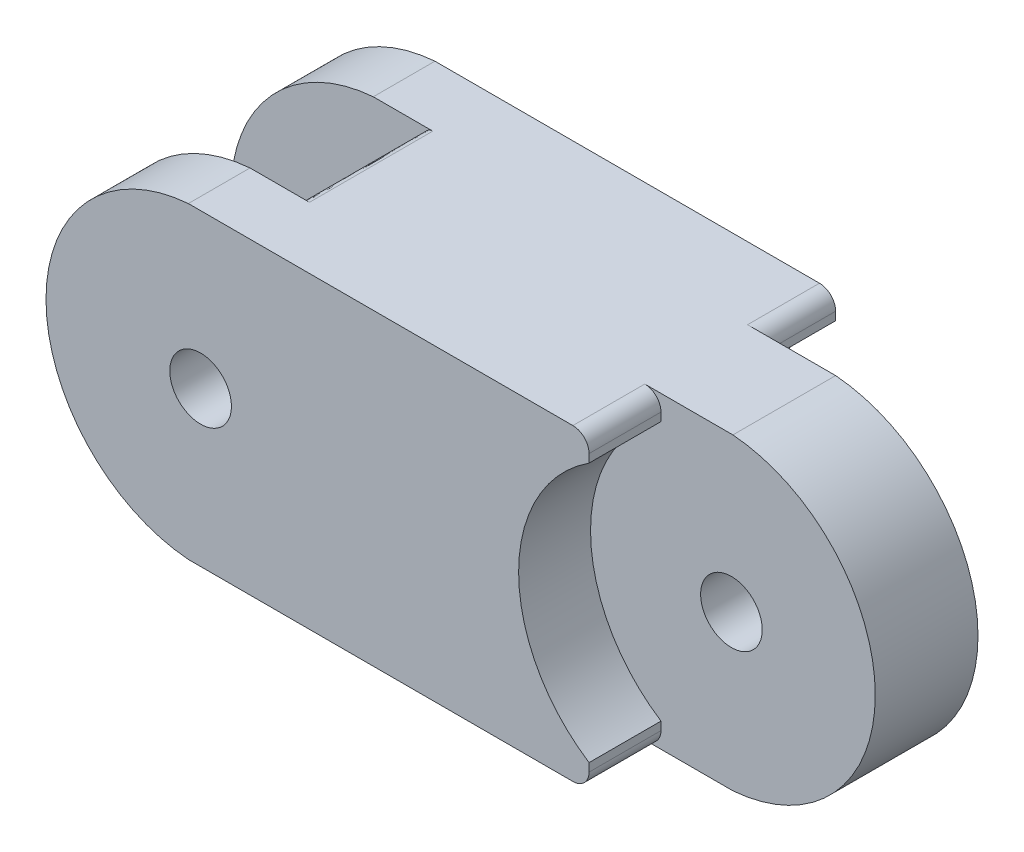
from build123d import *

# Parameters (mm, degrees)
SKETCH1_W               = 29.21
SKETCH1_H               = 15.24
BOSS_EXTRUDE1_DEPTH     = 19.05
BOSS_EXTRUDE2_DEPTH     = 3.175
BOSS_EXTRUDE3_DEPTH     = 3.81
LPATTERN1_COUNT         = 2
LPATTERN1_PITCH         = 11.43
SKETCH7_R               = 1.905
CUT_EXTRUDE2_DEPTH      = 8.62
CUT_EXTRUDE2_DEPTH_BACK = 8.62
CUT_EXTRUDE4_DEPTH      = 2.794
CUT_EXTRUDE4_DEPTH_BACK = 3.175
CUT_EXTRUDE5_DEPTH      = 5.842
CUT_EXTRUDE6_DEPTH      = 3.81
FILLET2_R               = 0.5
SKETCH16_R              = 1.905
CUT_EXTRUDE8_DEPTH      = 2.27
CUT_EXTRUDE8_DEPTH_BACK = 14.97
SKETCH17_W              = 4.445
SKETCH17_H              = 4.445
CUT_EXTRUDE9_DEPTH      = 19.05
LPATTERN2_COUNT         = 2
LPATTERN2_PITCH         = 10.795
FILLET4_R               = 1


with BuildPart() as part:
    # Sketch1 → Boss-Extrude1 (new body)
    with BuildSketch(Plane(origin=(0, 0, 0), x_dir=(1, 0, 0), z_dir=(0, 1, 0))):
        Rectangle(SKETCH1_W, SKETCH1_H)
    extrude(amount=BOSS_EXTRUDE1_DEPTH)

    # Sketch3 → Boss-Extrude2 (add, symmetric)
    with BuildSketch(Plane.XY):
        with BuildLine():
            Line((14.605, 19.05), (14.605, 0))
            ThreePointArc((14.605, 0), (23.403337922, 9.525), (14.605, 19.05))
        make_face()
    extrude(amount=BOSS_EXTRUDE2_DEPTH, both=True)

    # Sketch6 → Boss-Extrude3 (add)
    with BuildSketch(Plane.XY.offset(7.62)):
        with BuildLine():
            Line((-14.605, 19.05), (-14.605, 0))
            ThreePointArc((-14.605, 0), (-23.403337922, 9.525), (-14.605, 19.05))
        make_face()
    boss_extrude3 = extrude(amount=-BOSS_EXTRUDE3_DEPTH)

    # LPattern1: Boss-Extrude3 ×2
    with Locations(*[(0, 0, -i * LPATTERN1_PITCH) for i in range(1, LPATTERN1_COUNT)]):
        add(boss_extrude3)

    # Sketch7 → Cut-Extrude2 (cut, two sides)
    with BuildSketch(Plane.XY) as cut_extrude2_sk:
        with Locations((-13.848330108, 9.525)):
            Circle(SKETCH7_R)
    extrude(amount=CUT_EXTRUDE2_DEPTH, mode=Mode.SUBTRACT)
    extrude(cut_extrude2_sk.sketch, amount=-CUT_EXTRUDE2_DEPTH_BACK, mode=Mode.SUBTRACT)

    # Sketch9 → Cut-Extrude4 (cut, two sides)
    with BuildSketch(Plane.XY.offset(6.35)) as cut_extrude4_sk:
        with BuildLine():
            Line((14.605, 19.05), (14.605, 0))
            ThreePointArc((14.605, 0), (5.806662078, 9.525), (14.605, 19.05))
        make_face()
    extrude(amount=CUT_EXTRUDE4_DEPTH, mode=Mode.SUBTRACT)
    extrude(cut_extrude4_sk.sketch, amount=-CUT_EXTRUDE4_DEPTH_BACK, mode=Mode.SUBTRACT)

    # Sketch11 → Cut-Extrude5 (cut)
    with BuildSketch(Plane.XY.offset(-9.017)):
        with BuildLine():
            Line((14.605, 19.05), (14.605, 0))
            ThreePointArc((14.605, 0), (5.806662078, 9.525), (14.605, 19.05))
        make_face()
    extrude(amount=CUT_EXTRUDE5_DEPTH, mode=Mode.SUBTRACT)

    # Sketch12 → Cut-Extrude6 (cut, symmetric)
    with BuildSketch(Plane.XY):
        with BuildLine():
            Line((-14.605, 19.05), (-14.605, 0))
            ThreePointArc((-14.605, 0), (-5.806662078, 9.525), (-14.605, 19.05))
        make_face()
    extrude(amount=CUT_EXTRUDE6_DEPTH, both=True, mode=Mode.SUBTRACT)

    # Fillet2
    fillet2_edges = [part.edges().sort_by_distance(p)[0] for p in [
        (-14.605, 0, 0),
        (-14.605, 19.05, 0),
    ]]
    fillet(fillet2_edges, radius=FILLET2_R)

    # Sketch16 → Cut-Extrude8 (cut, two sides)
    with BuildSketch(Plane.XY.offset(6.35)) as cut_extrude8_sk:
        with Locations(Location((14.513337922, 9.525, 0), (0, 0, 180))):  # turned: the seam where the file's is
            Circle(SKETCH16_R)
    extrude(amount=CUT_EXTRUDE8_DEPTH, mode=Mode.SUBTRACT)
    extrude(cut_extrude8_sk.sketch, amount=-CUT_EXTRUDE8_DEPTH_BACK, mode=Mode.SUBTRACT)

    # Sketch17 → Cut-Extrude9 (cut)
    with BuildSketch(Plane(origin=(0, 19.05, 0), x_dir=(1, 0, 0), z_dir=(0, 1, 0))):
        with Locations((12.3825, 5.3975)):
            Rectangle(SKETCH17_W, SKETCH17_H)
    cut_extrude9 = extrude(amount=-CUT_EXTRUDE9_DEPTH, mode=Mode.SUBTRACT)

    # LPattern2: Cut-Extrude9 ×2
    with Locations(*[(0, 0, i * LPATTERN2_PITCH) for i in range(1, LPATTERN2_COUNT)]):
        add(cut_extrude9, mode=Mode.SUBTRACT)

    # Fillet4
    fillet4_edges = [part.edges().sort_by_distance(p)[0] for p in [
        (10.16, 19.05, -5.3975),
        (10.16, 0, -5.3975),
        (10.16, 0, 5.3975),
        (10.16, 19.05, 5.3975),
    ]]
    fillet(fillet4_edges, radius=FILLET4_R)


solid = part.part
